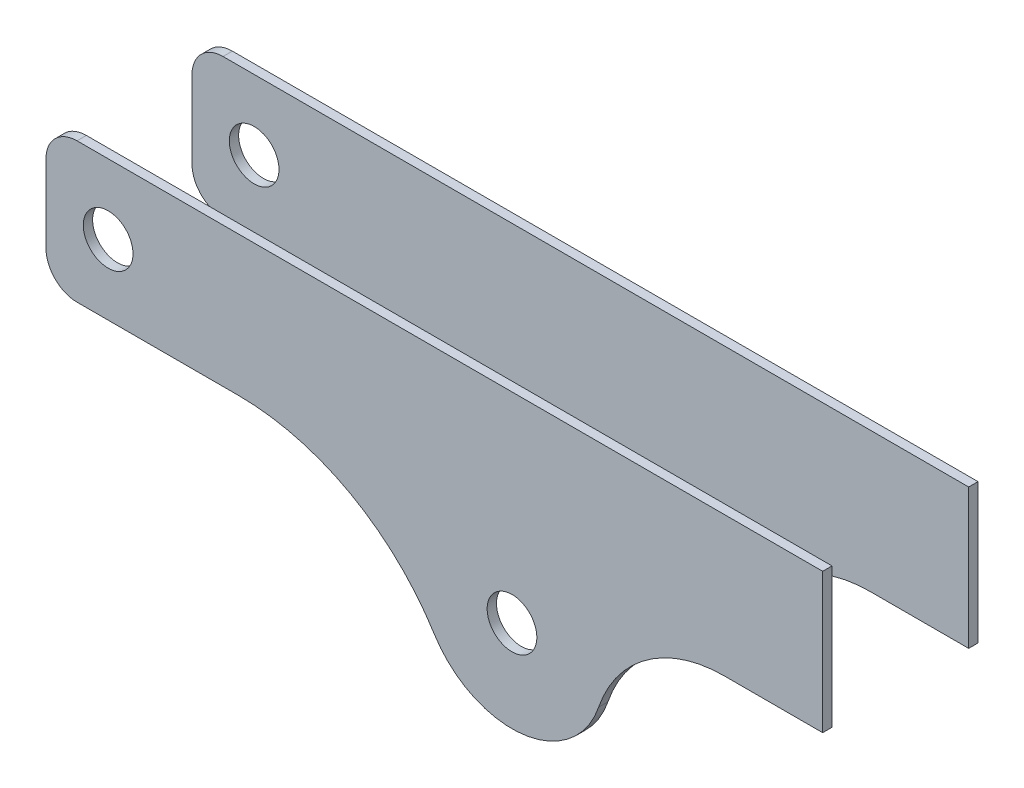
from build123d import *

# Parameters (mm, degrees)
SKETCH1_R           = 8
BOSS_EXTRUDE1_DEPTH = 3
SKETCH2_W           = 225
SKETCH2_H           = 3
BOSS_EXTRUDE2_DEPTH = 50
SKETCH3_R           = 8
BOSS_EXTRUDE3_DEPTH = 3
SKETCH4_R           = 2
CUT_EXTRUDE1_DEPTH  = 3
SKETCH5_W           = 225
SKETCH5_H           = 50.324774777
CUT_EXTRUDE2_DEPTH  = 3


with BuildPart() as part:
    # Sketch1 → Boss-Extrude1 (new body)
    with BuildSketch(Plane.XY):
        with BuildLine():
            Line((0, -10), (0, -35))
            ThreePointArc((0, -35), (2.928932188, -42.071067812), (10, -45))
            Line((10, -45), (61.832258709, -45))
            ThreePointArc((61.832258709, -45), (97.957481274, -54.348936041), (125.012434489, -80.04842664))
            ThreePointArc((125.012434489, -80.04842664), (153.377377511, -93.715687165), (177.882550256, -73.945494662))
            ThreePointArc((177.882550256, -73.945494662), (193.448136306, -52.982472122), (218.308062331, -45))
            Line((218.308062331, -45), (250, -45))
            Line((250, -45), (250, 0))
            Line((250, 0), (10, 0))
            ThreePointArc((10, 0), (2.928932188, -2.928932188), (0, -10))
        make_face()
        with Locations((20, -22.5)):
            Circle(SKETCH1_R, mode=Mode.SUBTRACT)
        with Locations((150, -64.457235549)):
            Circle(SKETCH1_R, mode=Mode.SUBTRACT)
    extrude(amount=BOSS_EXTRUDE1_DEPTH)

    # Sketch2 → Boss-Extrude2 (add)
    with BuildSketch(Plane.XY.offset(3)):
        with Locations((137.5, 1.5)):
            Rectangle(SKETCH2_W, SKETCH2_H)
    extrude(amount=-BOSS_EXTRUDE2_DEPTH)

    # Sketch3 → Boss-Extrude3 (add)
    with BuildSketch(Plane(origin=(0, 0, -47), x_dir=(-1, 0, 0), z_dir=(0, 0, -1))):
        with BuildLine():
            Line((-61.832258709, -45), (-10, -45))
            ThreePointArc((-10, -45), (-2.928932188, -42.071067812), (0, -35))
            Line((0, -35), (0, -10))
            ThreePointArc((0, -10), (-2.928932188, -2.928932188), (-10, 0))
            Line((-10, 0), (-25, 0))
            Line((-25, 0), (-250, 0))
            Line((-250, 0), (-250, -45))
            Line((-250, -45), (-218.308062331, -45))
            ThreePointArc((-218.308062331, -45), (-193.448136306, -52.982472122), (-177.882550256, -73.945494662))
            ThreePointArc((-177.882550256, -73.945494662), (-153.377377511, -93.715687165), (-125.012434489, -80.04842664))
            ThreePointArc((-125.012434489, -80.04842664), (-97.957481274, -54.348936041), (-61.832258709, -45))
        make_face()
        with Locations((-20, -22.5)):
            Circle(SKETCH3_R, mode=Mode.SUBTRACT)
        with Locations((-150, -64.457235549)):
            Circle(SKETCH3_R, mode=Mode.SUBTRACT)
    extrude(amount=-BOSS_EXTRUDE3_DEPTH)

    # Sketch4 → Cut-Extrude1 (cut)
    with BuildSketch(Plane(origin=(0, 3, 0), x_dir=(1, 0, 0), z_dir=(0, 1, 0))):
        with Locations((130, 34)):
            Circle(SKETCH4_R)
        with Locations((130, 10)):
            Circle(SKETCH4_R)
        with Locations((143, 34)):
            Circle(SKETCH4_R)
        with Locations((143, 10)):
            Circle(SKETCH4_R)
        with Locations((156, 34)):
            Circle(SKETCH4_R)
        with Locations((156, 10)):
            Circle(SKETCH4_R)
    extrude(amount=-CUT_EXTRUDE1_DEPTH, mode=Mode.SUBTRACT)

    # Sketch5 → Cut-Extrude2 (cut)
    with BuildSketch(Plane(origin=(0, 3, 0), x_dir=(1, 0, 0), z_dir=(0, 1, 0))):
        with Locations((137.5, 21.837612611)):
            Rectangle(SKETCH5_W, SKETCH5_H)
    extrude(amount=-CUT_EXTRUDE2_DEPTH, mode=Mode.SUBTRACT)


solid = part.part
